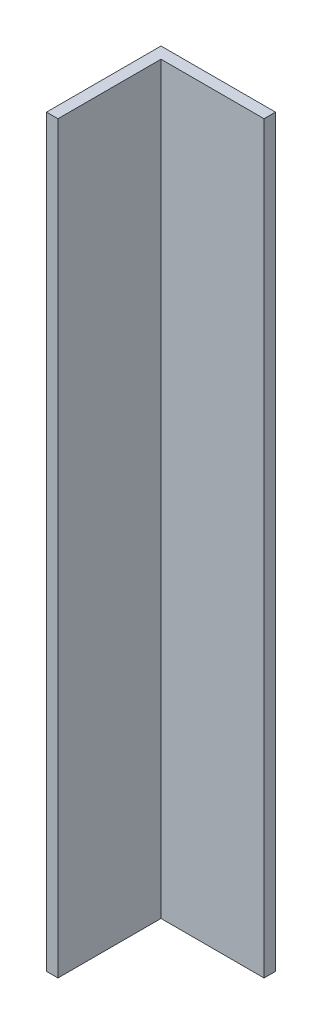
from build123d import *

# Parameters (mm, degrees)
SKETCH2_W           = 36
SKETCH2_H           = 260
BOSS_EXTRUDE1_DEPTH = 4
SKETCH2_3_W         = 4
SKETCH2_3_H         = 260
BOSS_EXTRUDE2_DEPTH = 40


with BuildPart() as part:
    # Sketch2 → Boss-Extrude1 (new body)
    with BuildSketch(Plane.XY):
        with Locations((2, 0)):
            Rectangle(SKETCH2_W, SKETCH2_H)
    extrude(amount=BOSS_EXTRUDE1_DEPTH)

    # Sketch2_3 → Boss-Extrude2 (add)
    with BuildSketch(Plane.XY):
        with Locations((-18, 0)):
            Rectangle(SKETCH2_3_W, SKETCH2_3_H)
    extrude(amount=BOSS_EXTRUDE2_DEPTH)


solid = part.part
